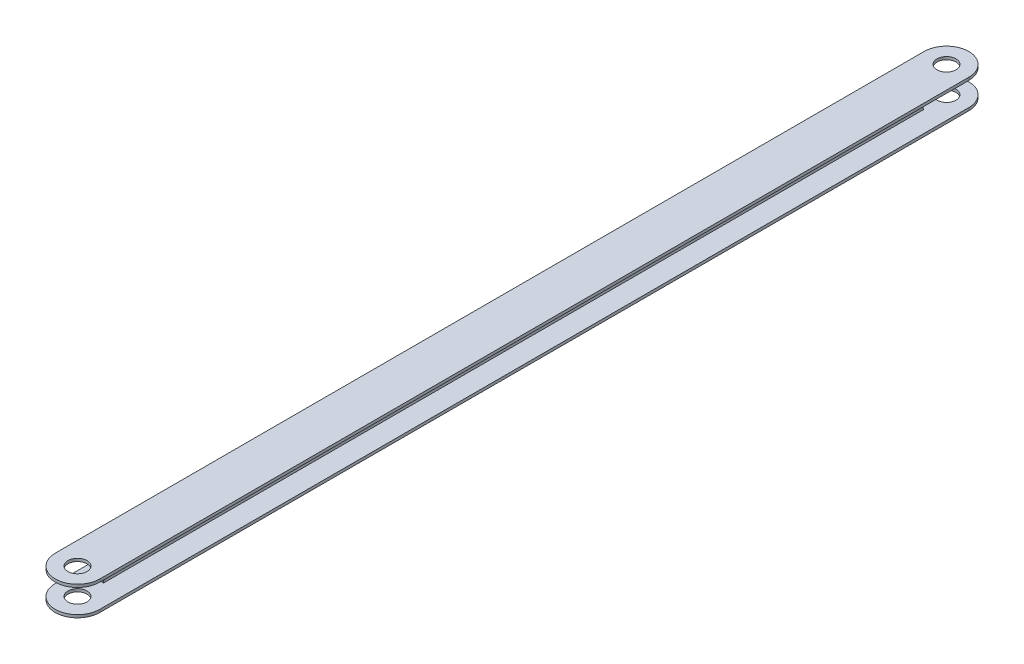
from build123d import *

# Parameters (mm, degrees)
SKETCH1_W           = 1.2
SKETCH1_H           = 10
SKETCH1_W_2         = 19
SKETCH1_H_2         = 1.2
BOSS_EXTRUDE1_DEPTH = 389
SKETCH3_R           = 4.05
CUT_EXTRUDE2_DEPTH  = 370
CUT_EXTRUDE4_DEPTH  = 370


with BuildPart() as part:
    # Sketch1 → Boss-Extrude1 (new body)
    with BuildSketch(Plane.XY):
        Rectangle(SKETCH1_W, SKETCH1_H)
        with Locations((0, -5.6)):
            Rectangle(SKETCH1_W_2, SKETCH1_H_2)
        with Locations((0, 5.6)):
            Rectangle(SKETCH1_W_2, SKETCH1_H_2)
    extrude(amount=BOSS_EXTRUDE1_DEPTH)

    # Sketch3 → Cut-Extrude2 (cut)
    with BuildSketch(Plane(origin=(0, 6.2, 0), x_dir=(1, 0, 0), z_dir=(0, 1, 0))):
        with BuildLine():
            Line((-9.5, 0), (-9.5, -9.5))
            ThreePointArc((-9.5, -9.5), (-6.717514436, -2.782485594), (-4.2e-08, 0))
            Line((-4.2e-08, 0), (-9.5, 0))
        make_face()
        with BuildLine():
            Line((9.5, 0), (-4.2e-08, 0))
            ThreePointArc((-4.2e-08, 0), (6.717514406, -2.782485564), (9.5, -9.5))
            Line((9.5, -9.5), (9.5, 0))
        make_face()
        with BuildLine():
            ThreePointArc((14.5, -9.5), (0, 5), (-14.5, -9.5))
            Line((-14.5, -9.5), (-9.5, -9.5))
            Line((-9.5, -9.5), (-9.5, 0))
            Line((-9.5, 0), (-4.2e-08, 0))
            Line((-4.2e-08, 0), (9.5, 0))
            Line((9.5, 0), (9.5, -9.5))
            Line((9.5, -9.5), (14.5, -9.5))
        make_face()
        with Locations((0, -9.5)):
            Circle(SKETCH3_R)
    cut_extrude2 = extrude(amount=-CUT_EXTRUDE2_DEPTH, mode=Mode.SUBTRACT)

    # Mirror1: Cut-Extrude2 across plane
    add(cut_extrude2.mirror(Plane.XY.offset(194.5)), mode=Mode.SUBTRACT)

    # Sketch6 → Cut-Extrude4 (cut)
    with BuildSketch(Plane.ZY.offset(0.6)):
        with BuildLine():
            Line((20, -5), (-1, -5))
            Line((-1, -5), (-1, 5))
            Line((-1, 5), (20, 5))
            Line((20, 5), (20, 4.517635543))
            ThreePointArc((20, 4.517635543), (20.154857723, 3.983094121), (20.571469063, 3.614108434))
            ThreePointArc((20.571469063, 3.614108434), (22.857345314, 0), (20.571469063, -3.614108434))
            ThreePointArc((20.571469063, -3.614108434), (20.154857723, -3.983094121), (20, -4.517635543))
            Line((20, -4.517635543), (20, -5))
        make_face()
    cut_extrude4 = extrude(amount=-CUT_EXTRUDE4_DEPTH, mode=Mode.SUBTRACT)

    # Mirror2: Cut-Extrude4 across plane
    add(cut_extrude4.mirror(Plane.XY.offset(194.5)), mode=Mode.SUBTRACT)


solid = part.part
